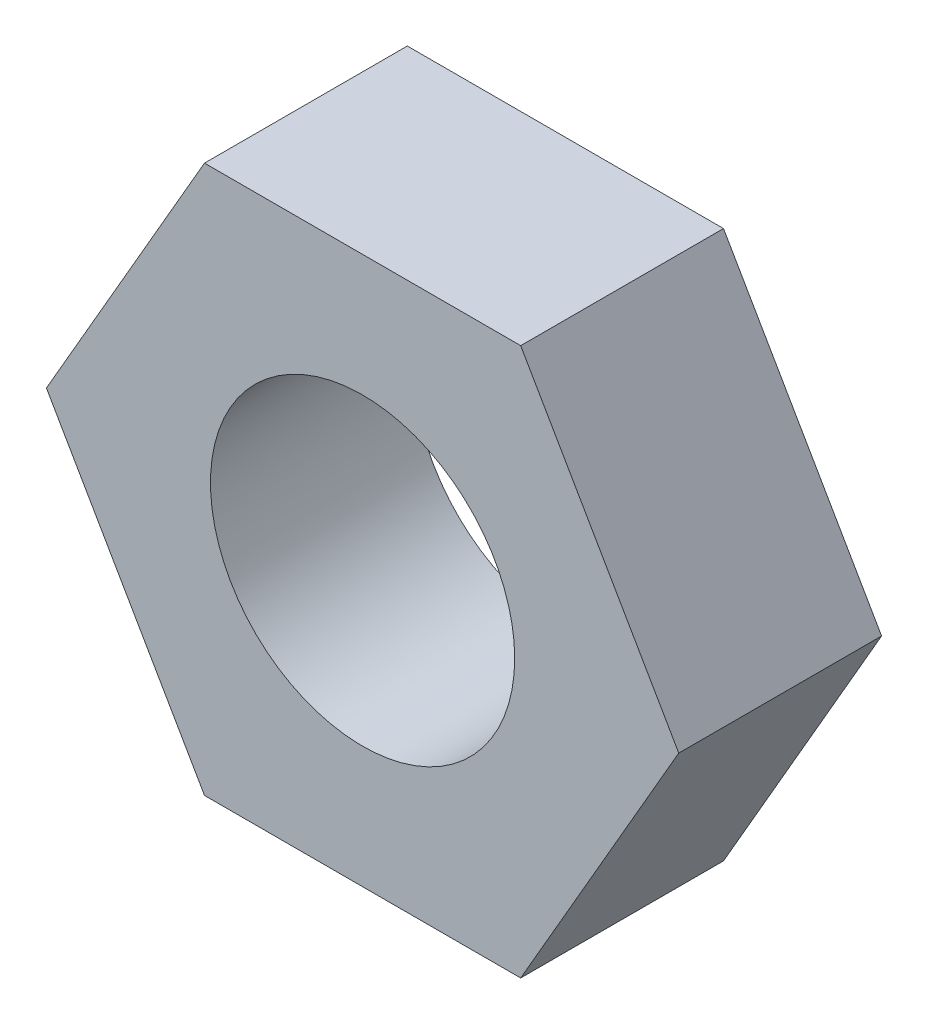
from build123d import *

# Parameters (mm, degrees)
SKETCH2_R           = 4.5
BOSS_EXTRUDE1_DEPTH = 6


with BuildPart() as part:
    # Sketch2 → Boss-Extrude1 (new body)
    with BuildSketch(Plane.XY):
        Polygon((4.67653718, 8.1), (-4.67653718, 8.1), (-9.353074361, 0), (-4.67653718, -8.1), (4.67653718, -8.1), (9.353074361, 0), align=None)
        Circle(SKETCH2_R, mode=Mode.SUBTRACT)
    extrude(amount=BOSS_EXTRUDE1_DEPTH)


solid = part.part
